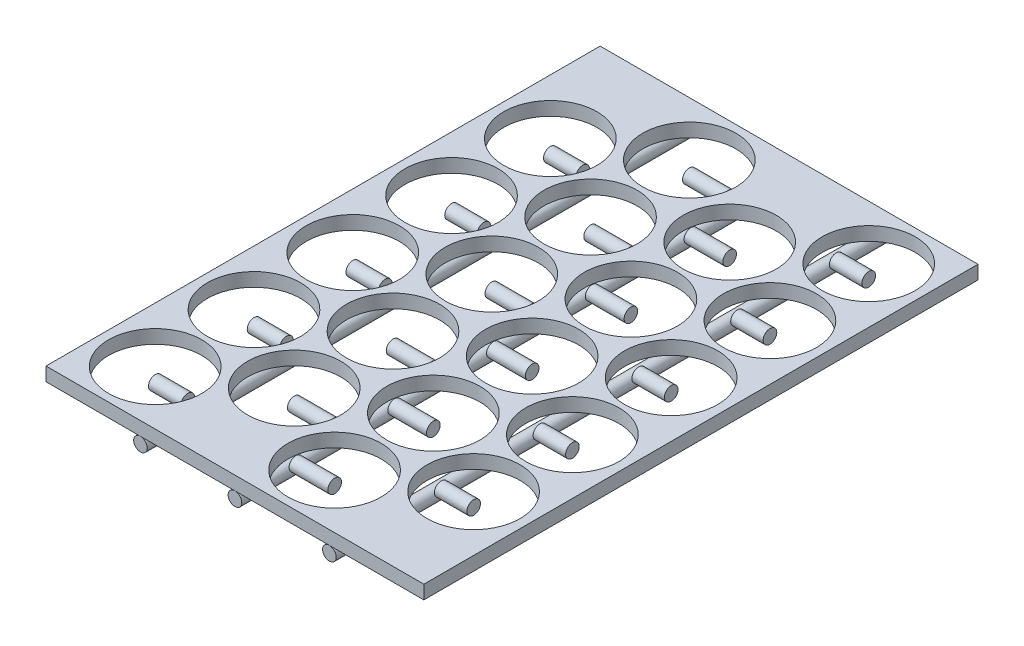
from build123d import *

# Parameters (mm, degrees)
SKETCH1_W           = 88
SKETCH1_H           = 129.049998998
SKETCH1_R           = 10.85
BOSS_EXTRUDE2_DEPTH = 3.175
SKETCH2_R           = 1.5875
BOSS_EXTRUDE3_DEPTH = 129.049999
SKETCH7_W           = 7.5625
SKETCH7_H           = 1.5875
LPATTERN2_COUNT     = 5
LPATTERN2_PITCH     = 23
SKETCH9_R           = 1.5875
BOSS_EXTRUDE4_DEPTH = 129.049999
SKETCH10_W          = 7.5625
SKETCH10_H          = 1.5875
LPATTERN3_COUNT     = 5
LPATTERN3_PITCH     = 23
SKETCH11_R          = 1.5875
BOSS_EXTRUDE5_DEPTH = 129.049999
SKETCH12_W          = 9.03769793
SKETCH12_H          = 1.5875
LPATTERN4_COUNT     = 5
LPATTERN4_PITCH     = 23
SKETCH13_W          = 9.03769793
SKETCH13_H          = 1.5875
LPATTERN5_COUNT     = 5
LPATTERN5_PITCH     = 23


with BuildPart() as part:
    # Sketch1 → Boss-Extrude2 (new body)
    with BuildSketch(Plane(origin=(0, 0, 0), x_dir=(1, 0, 0), z_dir=(0, 1, 0))):
        with Locations((22, 0)):
            Rectangle(SKETCH1_W, SKETCH1_H)
        with Locations((-9.169208279, -51.924999499)):
            Circle(SKETCH1_R, mode=Mode.SUBTRACT)
        with Locations((11.355593791, -40.074999499)):
            Circle(SKETCH1_R, mode=Mode.SUBTRACT)
        with Locations((-9.164406209, -28.924999749)):
            Circle(SKETCH1_R, mode=Mode.SUBTRACT)
        with Locations((-9.159604139, -5.925)):
            Circle(SKETCH1_R, mode=Mode.SUBTRACT)
        with Locations((11.360395861, -17.074999749)):
            Circle(SKETCH1_R, mode=Mode.SUBTRACT)
        with Locations((32.605989652, -51.924999499)):
            Circle(SKETCH1_R, mode=Mode.SUBTRACT)
        with Locations((53.130791721, -40.074999499)):
            Circle(SKETCH1_R, mode=Mode.SUBTRACT)
        with Locations((32.610791721, -28.924999749)):
            Circle(SKETCH1_R, mode=Mode.SUBTRACT)
        with Locations((32.615593791, -5.925)):
            Circle(SKETCH1_R, mode=Mode.SUBTRACT)
        with Locations((53.135593791, -17.074999749)):
            Circle(SKETCH1_R, mode=Mode.SUBTRACT)
        with Locations((-9.15480207, 17.074999749)):
            Circle(SKETCH1_R, mode=Mode.SUBTRACT)
        with Locations((11.36519793, 5.925)):
            Circle(SKETCH1_R, mode=Mode.SUBTRACT)
        with Locations((11.37, 28.924999749)):
            Circle(SKETCH1_R, mode=Mode.SUBTRACT)
        with Locations((-9.15, 40.074999499)):
            Circle(SKETCH1_R, mode=Mode.SUBTRACT)
        with Locations((11.37480207, 51.924999499)):
            Circle(SKETCH1_R, mode=Mode.SUBTRACT)
        with Locations((32.620395861, 17.074999749)):
            Circle(SKETCH1_R, mode=Mode.SUBTRACT)
        with Locations((53.140395861, 5.925)):
            Circle(SKETCH1_R, mode=Mode.SUBTRACT)
        with Locations((53.14519793, 28.924999749)):
            Circle(SKETCH1_R, mode=Mode.SUBTRACT)
        with Locations((32.62519793, 40.074999499)):
            Circle(SKETCH1_R, mode=Mode.SUBTRACT)
        with Locations((53.15, 51.924999499)):
            Circle(SKETCH1_R, mode=Mode.SUBTRACT)
    extrude(amount=BOSS_EXTRUDE2_DEPTH)


with BuildPart() as body_2:
    # Sketch2 → Boss-Extrude3 (new body)
    with BuildSketch(Plane.XY.offset(64.524999499)):
        with Locations((0, -1.5875)):
            Circle(SKETCH2_R)
    extrude(amount=-BOSS_EXTRUDE3_DEPTH)


with BuildPart() as body_3:
    # Sketch7 → Revolve4 (revolve)
    with BuildSketch(Plane(origin=(0, 0, 0), x_dir=(1, 0, 0), z_dir=(0, 1, 0))):
        with Locations((-5.36875, 40.868749499)):
            Rectangle(SKETCH7_W, SKETCH7_H)
    revolve(axis=Axis((-9.15, 0, -40.074999499), (1, 0, 0)))


with BuildPart() as lpattern2_1:
    # LPattern2: pattern copy
    add(body_3.part.moved(Location(Vector(0, 0, 1) * (1 * LPATTERN2_PITCH))))


with BuildPart() as lpattern2_2:
    # LPattern2: pattern copy
    add(body_3.part.moved(Location(Vector(0, 0, 1) * (2 * LPATTERN2_PITCH))))


with BuildPart() as lpattern2_3:
    # LPattern2: pattern copy
    add(body_3.part.moved(Location(Vector(0, 0, 1) * (3 * LPATTERN2_PITCH))))


with BuildPart() as lpattern2_4:
    # LPattern2: pattern copy
    add(body_3.part.moved(Location(Vector(0, 0, 1) * (4 * LPATTERN2_PITCH))))


with BuildPart() as body_8:
    # Sketch9 → Boss-Extrude4 (new body)
    with BuildSketch(Plane.XY.offset(64.524999499)):
        with Locations((44, -1.5875)):
            Circle(SKETCH9_R)
    extrude(amount=-BOSS_EXTRUDE4_DEPTH)


with BuildPart() as body_9:
    # Sketch10 → Revolve5 (revolve)
    with BuildSketch(Plane(origin=(0, 0, 0), x_dir=(1, 0, 0), z_dir=(0, 1, 0))):
        with Locations((49.36875, 52.718749499)):
            Rectangle(SKETCH10_W, SKETCH10_H)
    revolve(axis=Axis((53.15, 0, -51.924999499), (-1, 0, 0)))


with BuildPart() as lpattern3_1:
    # LPattern3: pattern copy
    add(body_9.part.moved(Location(Vector(0, 0, 1) * (1 * LPATTERN3_PITCH))))


with BuildPart() as lpattern3_2:
    # LPattern3: pattern copy
    add(body_9.part.moved(Location(Vector(0, 0, 1) * (2 * LPATTERN3_PITCH))))


with BuildPart() as lpattern3_3:
    # LPattern3: pattern copy
    add(body_9.part.moved(Location(Vector(0, 0, 1) * (3 * LPATTERN3_PITCH))))


with BuildPart() as lpattern3_4:
    # LPattern3: pattern copy
    add(body_9.part.moved(Location(Vector(0, 0, 1) * (4 * LPATTERN3_PITCH))))


with BuildPart() as body_14:
    # Sketch11 → Boss-Extrude5 (new body)
    with BuildSketch(Plane.XY.offset(64.524999499)):
        with Locations((22, -1.5875)):
            Circle(SKETCH11_R)
    extrude(amount=-BOSS_EXTRUDE5_DEPTH)


with BuildPart() as body_15:
    # Sketch12 → Revolve6 (revolve)
    with BuildSketch(Plane(origin=(0, 0, 0), x_dir=(1, 0, 0), z_dir=(0, 1, 0))):
        with Locations((15.893651035, 52.718749499)):
            Rectangle(SKETCH12_W, SKETCH12_H)
    revolve(axis=Axis((11.37480207, 0, -51.924999499), (1, 0, 0)))


with BuildPart() as lpattern4_1:
    # LPattern4: pattern copy
    add(body_15.part.moved(Location(Vector(0, 0, 1) * (1 * LPATTERN4_PITCH))))


with BuildPart() as lpattern4_2:
    # LPattern4: pattern copy
    add(body_15.part.moved(Location(Vector(0, 0, 1) * (2 * LPATTERN4_PITCH))))


with BuildPart() as lpattern4_3:
    # LPattern4: pattern copy
    add(body_15.part.moved(Location(Vector(0, 0, 1) * (3 * LPATTERN4_PITCH))))


with BuildPart() as lpattern4_4:
    # LPattern4: pattern copy
    add(body_15.part.moved(Location(Vector(0, 0, 1) * (4 * LPATTERN4_PITCH))))


with BuildPart() as body_20:
    # Sketch13 → Revolve7 (revolve)
    with BuildSketch(Plane(origin=(0, 0, 0), x_dir=(1, 0, 0), z_dir=(0, 1, 0))):
        with Locations((28.106348965, 40.868749499)):
            Rectangle(SKETCH13_W, SKETCH13_H)
    revolve(axis=Axis((32.62519793, 0, -40.074999499), (-1, 0, 0)))


with BuildPart() as lpattern5_1:
    # LPattern5: pattern copy
    add(body_20.part.moved(Location(Vector(0, 0, 1) * (1 * LPATTERN5_PITCH))))


with BuildPart() as lpattern5_2:
    # LPattern5: pattern copy
    add(body_20.part.moved(Location(Vector(0, 0, 1) * (2 * LPATTERN5_PITCH))))


with BuildPart() as lpattern5_3:
    # LPattern5: pattern copy
    add(body_20.part.moved(Location(Vector(0, 0, 1) * (3 * LPATTERN5_PITCH))))


with BuildPart() as lpattern5_4:
    # LPattern5: pattern copy
    add(body_20.part.moved(Location(Vector(0, 0, 1) * (4 * LPATTERN5_PITCH))))


solid = Compound([part.part, body_2.part, body_3.part, lpattern2_1.part, lpattern2_2.part, lpattern2_3.part, lpattern2_4.part, body_8.part, body_9.part, lpattern3_1.part, lpattern3_2.part, lpattern3_3.part, lpattern3_4.part, body_14.part, body_15.part, lpattern4_1.part, lpattern4_2.part, lpattern4_3.part, lpattern4_4.part, body_20.part, lpattern5_1.part, lpattern5_2.part, lpattern5_3.part, lpattern5_4.part])
